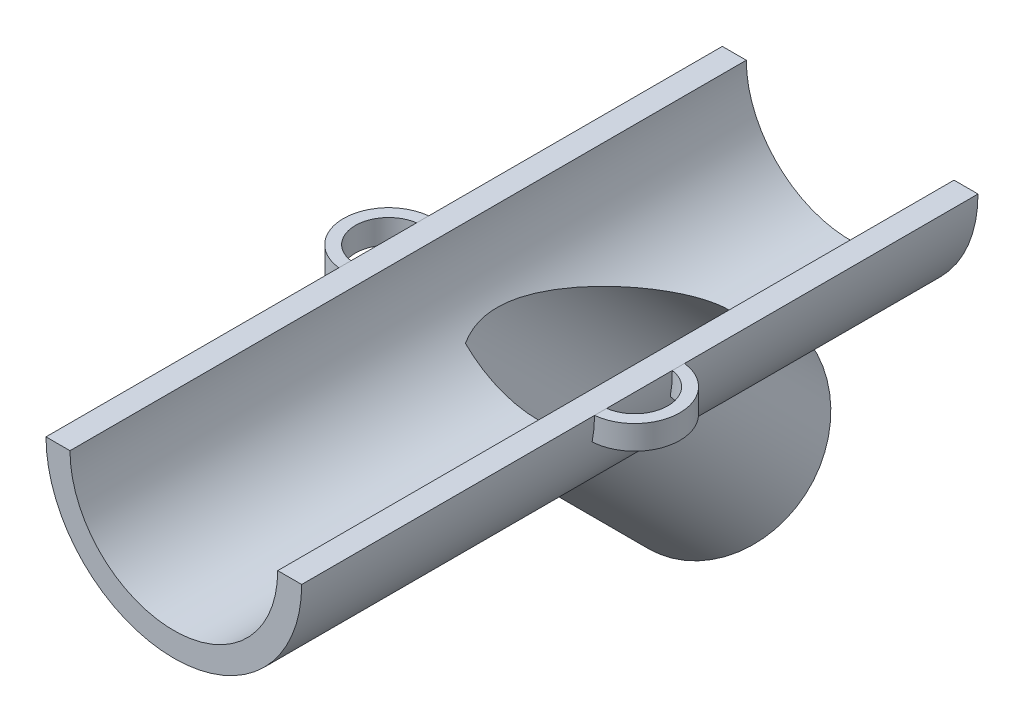
from build123d import *

# Parameters (mm, degrees)
BOSS_EXTRUDE1_DEPTH      = 76.2
BOSS_EXTRUDE4_REACH      = 80.569
BOSS_EXTRUDE4_END_RADIUS = 13.54
SKETCH4_R                = 10
SKETCH9_R                = 8.5
CUT_EXTRUDE4_DEPTH       = 94.242153775
CUT_EXTRUDE4_DEPTH_BACK  = 94.242153775
CUT_EXTRUDE5_DEPTH       = 43.18
BOSS_EXTRUDE5_DEPTH      = 25.4
BOSS_EXTRUDE6_DEPTH      = 2.54
BOSS_EXTRUDE6_2_DEPTH    = 2.54
SKETCH14_R               = 10
CUT_EXTRUDE6_DEPTH       = 25.4
BOSS_EXTRUDE7_DEPTH      = 13.208


with BuildPart() as part:
    # Sketch2 → Boss-Extrude1 (new body)
    with BuildSketch(Plane.XY):
        with BuildLine():
            Line((13.54, 0), (11, 0))
            ThreePointArc((11, 0), (0, -11), (-11, 0))
            Line((-11, 0), (-13.54, 0))
            ThreePointArc((-13.54, 0), (0, -13.54), (13.54, 0))
        make_face()
    extrude(amount=BOSS_EXTRUDE1_DEPTH)

    # Boss-Extrude4: up to this cylinder (the profile starts outside it)
    boss_extrude4_end = Plane(origin=(0, 0, 39.513127), z_dir=(0, 0, -1)) * Cylinder(BOSS_EXTRUDE4_END_RADIUS, 189.218, mode=Mode.PRIVATE)
    # Sketch4 → Boss-Extrude4 (add, up to the surface)
    with BuildSketch(Plane(origin=(0, 0, 0), x_dir=(-1, 0, 0), z_dir=(0, 0.7071067811865561, 0.7071067811865389)), mode=Mode.PRIVATE) as boss_extrude4_sk1:
        with Locations(Location((0, 55.88, 0), (0, 0, 33.774019763))):
            Circle(SKETCH4_R)
    boss_extrude4_tool1 = extrude(boss_extrude4_sk1.sketch, amount=BOSS_EXTRUDE4_REACH, mode=Mode.PRIVATE) - boss_extrude4_end
    add(boss_extrude4_tool1.solids().sort_by_distance((0, -39.513127, 39.513127))[0])

    # Sketch9 → Cut-Extrude4 (cut, two sides)
    with BuildSketch(Plane(origin=(0, 0, 0), x_dir=(-1, 0, 0), z_dir=(0, -0.7071067811865562, -0.7071067811865389))) as cut_extrude4_sk:
        with Locations(Location((0, -55.88, 0), (0, 0, 204.578729369))):
            Circle(SKETCH9_R)
    extrude(amount=CUT_EXTRUDE4_DEPTH, mode=Mode.SUBTRACT)
    extrude(cut_extrude4_sk.sketch, amount=-CUT_EXTRUDE4_DEPTH_BACK, mode=Mode.SUBTRACT)

    # Sketch10 → Cut-Extrude5 (cut)
    with BuildSketch(Plane(origin=(0, 0, 0), x_dir=(-1, 0, 0), z_dir=(0, 0, -1))):
        with BuildLine():
            Line((13.54, 0), (11, 0))
            ThreePointArc((11, 0), (0, -11), (-11, 0))
            Line((-11, 0), (-13.54, 0))
            ThreePointArc((-13.54, 0), (0, -13.54), (13.54, 0))
        make_face()
    extrude(amount=-CUT_EXTRUDE5_DEPTH, mode=Mode.SUBTRACT)

    # Sketch11 → Boss-Extrude5 (add)
    with BuildSketch(Plane.XY.offset(76.2)):
        with BuildLine():
            Line((13.54, 0), (11, 0))
            ThreePointArc((11, 0), (0, -11), (-11, 0))
            Line((-11, 0), (-13.54, 0))
            ThreePointArc((-13.54, 0), (0, -13.54), (13.54, 0))
        make_face()
    extrude(amount=BOSS_EXTRUDE5_DEPTH)

    # Sketch14 → Cut-Extrude6 (cut)
    with BuildSketch(Plane(origin=(0, 0, 0), x_dir=(1, 0, 0), z_dir=(0, -0.7071067811865562, -0.7071067811865389))):
        with Locations(Location((0, 55.88, 0), (0, 0, 270))):
            Circle(SKETCH14_R)
    extrude(amount=-CUT_EXTRUDE6_DEPTH, mode=Mode.SUBTRACT)

    # Sketch15 → Boss-Extrude7 (add)
    with BuildSketch(Plane.XY.offset(101.6)):
        with BuildLine():
            Line((13.54, 0), (11, 0))
            ThreePointArc((11, 0), (0, -11), (-11, 0))
            Line((-11, 0), (-13.54, 0))
            ThreePointArc((-13.54, 0), (0, -13.54), (13.54, 0))
        make_face()
    extrude(amount=BOSS_EXTRUDE7_DEPTH)


with BuildPart() as body_2:
    # Sketch12 → Boss-Extrude6 (new body)
    with BuildSketch(Plane(origin=(0, 0, 0), x_dir=(1, 0, 0), z_dir=(0, 1, 0))):
        with BuildLine():
            Line((-13.032, -83.82), (-13.032, -82.55))
            ThreePointArc((-13.032, -82.55), (-16.54899091, -79.03300909), (-13.032, -75.51601818))
            Line((-13.032, -75.51601818), (-13.032, -74.24601818))
            ThreePointArc((-13.032, -74.24601818), (-17.81899091, -79.03300909), (-13.032, -83.82))
        make_face()
    extrude(amount=-BOSS_EXTRUDE6_DEPTH)


with BuildPart() as body_3:
    # Sketch12 → Boss-Extrude6 2 (new body)
    with BuildSketch(Plane(origin=(0, 0, 0), x_dir=(1, 0, 0), z_dir=(0, 1, 0))):
        with BuildLine():
            Line((13.032, -74.24601818), (13.032, -75.51601818))
            ThreePointArc((13.032, -75.51601818), (16.54899091, -79.03300909), (13.032, -82.55))
            Line((13.032, -82.55), (13.032, -83.82))
            ThreePointArc((13.032, -83.82), (17.81899091, -79.03300909), (13.032, -74.24601818))
        make_face()
    extrude(amount=-BOSS_EXTRUDE6_2_DEPTH)


solid = Compound([part.part, body_2.part, body_3.part])
